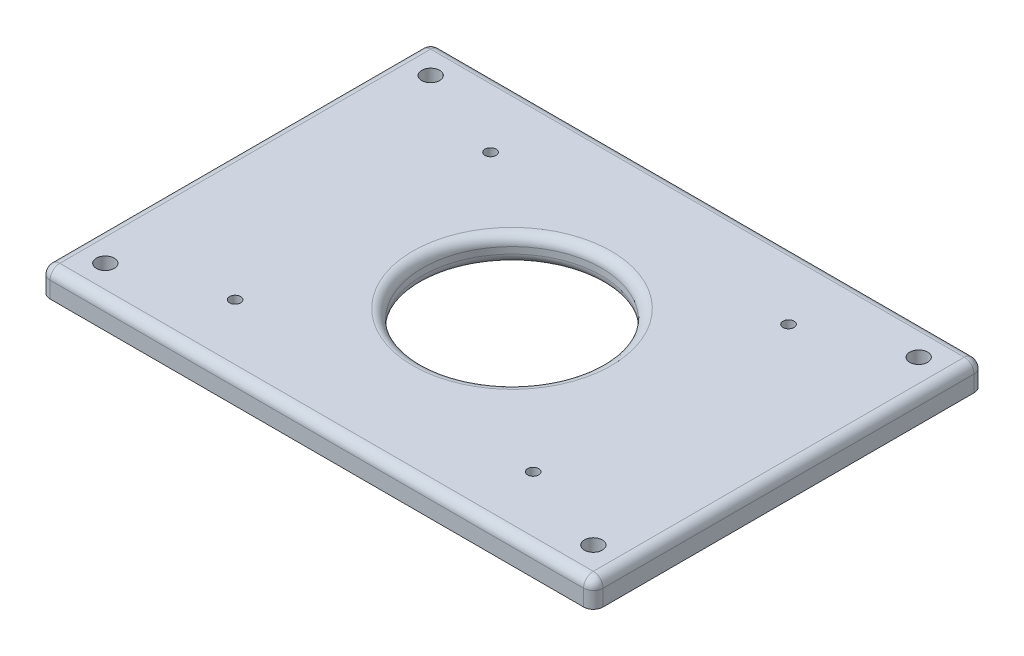
from build123d import *

# Parameters (mm, degrees)
BOSS_EXTRUDE1_DEPTH = 170
SKETCH2_R           = 2.75
CUT_EXTRUDE1_DEPTH  = 9
SKETCH3_R           = 1.7
CUT_EXTRUDE2_DEPTH  = 9
SKETCH4_R           = 3.375
CUT_EXTRUDE3_DEPTH  = 3.5
FILLET1_R           = 3
SKETCH5_R           = 27.5
CUT_EXTRUDE4_DEPTH  = 9
FILLET2_R           = 3
FILLET3_R           = 3
SKETCH6_W           = 170
SKETCH6_H           = 25
CUT_EXTRUDE5_DEPTH  = 9
FILLET4_R           = 3
FILLET5_R           = 3


with BuildPart() as part:
    # Sketch1 → Boss-Extrude1 (new body)
    with BuildSketch(Plane.XY):
        Polygon((-85, 0), (0, 0), (85, 0), (85, -8), (-85, -8), align=None)
    extrude(amount=-BOSS_EXTRUDE1_DEPTH)

    # Sketch2 → Cut-Extrude1 (cut, through all)
    with BuildSketch(Plane(origin=(0, 0, 0), x_dir=(1, 0, 0), z_dir=(0, 1, 0))):
        with Locations((-75, 35)):
            Circle(SKETCH2_R)
        with Locations((75, 35)):
            Circle(SKETCH2_R)
        with Locations((75, 135)):
            Circle(SKETCH2_R)
        with Locations((-75, 135)):
            Circle(SKETCH2_R)
    extrude(amount=-CUT_EXTRUDE1_DEPTH, mode=Mode.SUBTRACT)

    # Sketch3 → Cut-Extrude2 (cut, through all)
    with BuildSketch(Plane(origin=(0, 0, 0), x_dir=(1, 0, 0), z_dir=(0, 1, 0))):
        with Locations((-45.35, 45.25)):
            Circle(SKETCH3_R)
        with Locations((46.25, 45.25)):
            Circle(SKETCH3_R)
        with Locations((46.25, 123.75)):
            Circle(SKETCH3_R)
        with Locations((-45.35, 123.75)):
            Circle(SKETCH3_R)
    extrude(amount=-CUT_EXTRUDE2_DEPTH, mode=Mode.SUBTRACT)

    # Sketch4 → Cut-Extrude3 (cut)
    with BuildSketch(Plane.XZ.offset(8)):
        with Locations((-45.35, -45.25)):
            Circle(SKETCH4_R)
        with Locations((46.25, -45.25)):
            Circle(SKETCH4_R)
        with Locations((46.25, -123.75)):
            Circle(SKETCH4_R)
        with Locations((-45.35, -123.75)):
            Circle(SKETCH4_R)
    extrude(amount=-CUT_EXTRUDE3_DEPTH, mode=Mode.SUBTRACT)

    # Fillet1
    fillet1_edges = [part.edges().sort_by_distance(p)[0] for p in [
        (0, 0, -170),
        (0, 0, 0),
        (-85, 0, -85),
        (85, 0, -85),
    ]]
    fillet(fillet1_edges, radius=FILLET1_R)

    # Sketch5 → Cut-Extrude4 (cut, through all)
    with BuildSketch(Plane(origin=(0, 0, 0), x_dir=(1, 0, 0), z_dir=(0, 1, 0))):
        with Locations((-0.5, 85.5)):
            Circle(SKETCH5_R)
    extrude(amount=-CUT_EXTRUDE4_DEPTH, mode=Mode.SUBTRACT)

    # Fillet2
    fillet2_edges = [part.edges().sort_by_distance(p)[0] for p in [
        (-28, 0, -85.5),
    ]]
    fillet(fillet2_edges, radius=FILLET2_R)

    # Fillet3
    fillet3_edges = [part.edges().sort_by_distance(p)[0] for p in [
        (-28, -8, -85.5),
    ]]
    fillet(fillet3_edges, radius=FILLET3_R)

    # Sketch6 → Cut-Extrude5 (cut, through all)
    with BuildSketch(Plane(origin=(0, 0, 0), x_dir=(1, 0, 0), z_dir=(0, 1, 0))):
        with Locations((0, 157.5)):
            Rectangle(SKETCH6_W, SKETCH6_H)
        with Locations((0, 12.5)):
            Rectangle(SKETCH6_W, SKETCH6_H)
    extrude(amount=-CUT_EXTRUDE5_DEPTH, mode=Mode.SUBTRACT)

    # Fillet4
    fillet4_edges = [part.edges().sort_by_distance(p)[0] for p in [
        (0, 0, -145),
        (-85, -5.5, -145),
        (85, -5.5, -145),
    ]]
    fillet(fillet4_edges, radius=FILLET4_R)

    # Fillet5
    fillet5_edges = [part.edges().sort_by_distance(p)[0] for p in [
        (85, -5.5, -25),
        (-85, -5.5, -25),
        (0, 0, -25),
    ]]
    fillet(fillet5_edges, radius=FILLET5_R)


solid = part.part
